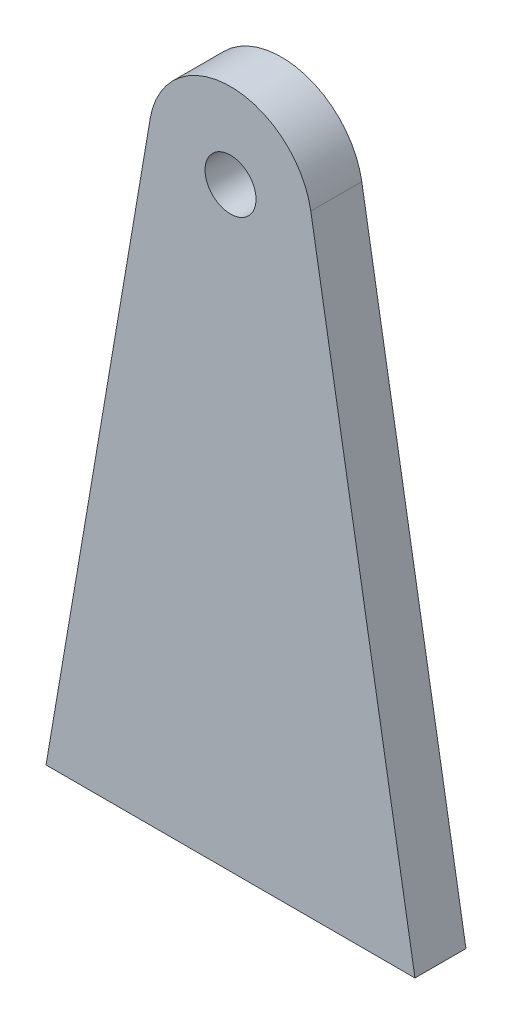
from build123d import *

# Parameters (mm, degrees)
SKETCH1_R           = 1.5
BOSS_EXTRUDE1_DEPTH = 3


with BuildPart() as part:
    # Sketch1 → Boss-Extrude1 (new body)
    with BuildSketch(Plane.XY):
        with BuildLine():
            Line((10.853563951, -24.90575827), (-10.853563951, -24.90575827))
            Line((-10.853563951, -24.90575827), (-4.723810622, 11.106542541))
            ThreePointArc((-4.723810622, 11.106542541), (-3.090959868, 13.964026902), (0, 15.09424173))
            ThreePointArc((0, 15.09424173), (3.090959868, 13.964026902), (4.723810622, 11.106542541))
            Line((4.723810622, 11.106542541), (10.853563951, -24.90575827))
        make_face()
        with Locations((0, 10.09424173)):
            Circle(SKETCH1_R, mode=Mode.SUBTRACT)
    extrude(amount=BOSS_EXTRUDE1_DEPTH)


solid = part.part
